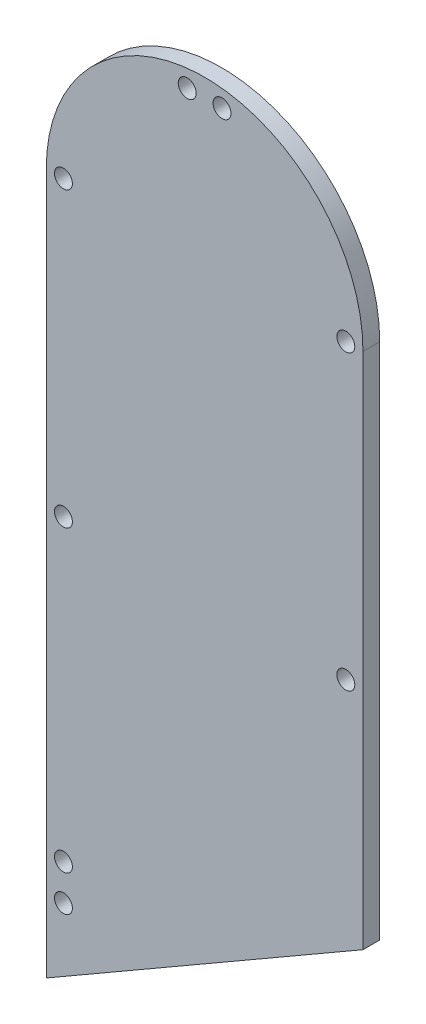
from build123d import *

# Parameters (mm, degrees)
SKETCH2_R           = 1.7
BOSS_EXTRUDE1_DEPTH = 3.175
CUT_EXTRUDE1_DEPTH  = 4.175


with BuildPart() as part:
    # Sketch2 → Boss-Extrude1 (new body)
    with BuildSketch(Plane.XY):
        with BuildLine():
            Line((54.582717937, -59.58290593), (54.582717937, 171.394622999))
            ThreePointArc((54.582717937, 171.394622999), (24.582717937, 201.394622999), (-5.417282063, 171.394622999))
            Line((-5.417282063, 171.394622999), (-5.417282063, -59.58290593))
            ThreePointArc((-5.417282063, -59.58290593), (24.582717937, -89.58290593), (54.582717937, -59.58290593))
        make_face()
        with Locations((27.882717937, 197.940291196)):
            Circle(SKETCH2_R, mode=Mode.SUBTRACT)
        with Locations((-2.167282063, -59.58290593)):
            Circle(SKETCH2_R, mode=Mode.SUBTRACT)
        with Locations((5.667611541, -78.498012327)):
            Circle(SKETCH2_R, mode=Mode.SUBTRACT)
        with Locations((21.182717937, -86.115951364)):
            Circle(SKETCH2_R, mode=Mode.SUBTRACT)
        with Locations((51.332717937, 171.394622999)):
            Circle(SKETCH2_R, mode=Mode.SUBTRACT)
        with Locations((-2.167282063, 59.305858535)):
            Circle(SKETCH2_R, mode=Mode.SUBTRACT)
        with Locations((27.982717937, -86.115951364)):
            Circle(SKETCH2_R, mode=Mode.SUBTRACT)
        with Locations((-2.167282063, 171.394622999)):
            Circle(SKETCH2_R, mode=Mode.SUBTRACT)
        with Locations((51.332717937, 115.905858535)):
            Circle(SKETCH2_R, mode=Mode.SUBTRACT)
        with Locations((-2.167282063, 115.905858535)):
            Circle(SKETCH2_R, mode=Mode.SUBTRACT)
        with Locations((43.497824334, -78.498012327)):
            Circle(SKETCH2_R, mode=Mode.SUBTRACT)
        with Locations((51.332717937, -59.58290593)):
            Circle(SKETCH2_R, mode=Mode.SUBTRACT)
        with Locations((51.332717937, -34.094141465)):
            Circle(SKETCH2_R, mode=Mode.SUBTRACT)
        with Locations((-2.167282063, -34.094141465)):
            Circle(SKETCH2_R, mode=Mode.SUBTRACT)
        with Locations((51.332717937, -4.094141465)):
            Circle(SKETCH2_R, mode=Mode.SUBTRACT)
        with Locations((-2.167282063, -4.094141465)):
            Circle(SKETCH2_R, mode=Mode.SUBTRACT)
        with Locations((51.332717937, 25.905858535)):
            Circle(SKETCH2_R, mode=Mode.SUBTRACT)
        with Locations((-2.167282063, 25.905858535)):
            Circle(SKETCH2_R, mode=Mode.SUBTRACT)
        with Locations((21.282717937, 197.940291196)):
            Circle(SKETCH2_R, mode=Mode.SUBTRACT)
        with Locations((51.332717937, 52.505858535)):
            Circle(SKETCH2_R, mode=Mode.SUBTRACT)
        with Locations((51.332717937, 59.305858535)):
            Circle(SKETCH2_R, mode=Mode.SUBTRACT)
        with Locations((-2.167282063, 52.505858535)):
            Circle(SKETCH2_R, mode=Mode.SUBTRACT)
    extrude(amount=BOSS_EXTRUDE1_DEPTH)

    # Sketch3 → Cut-Extrude1 (cut, through all)
    with BuildSketch(Plane.XY.offset(3.175)):
        Polygon((-23.178598576, 28.330849589), (72.344034451, 83.480867481), (72.344034451, -133.046541286), (-23.178598576, -133.046541286), align=None)
    extrude(amount=-CUT_EXTRUDE1_DEPTH, mode=Mode.SUBTRACT)


solid = part.part
